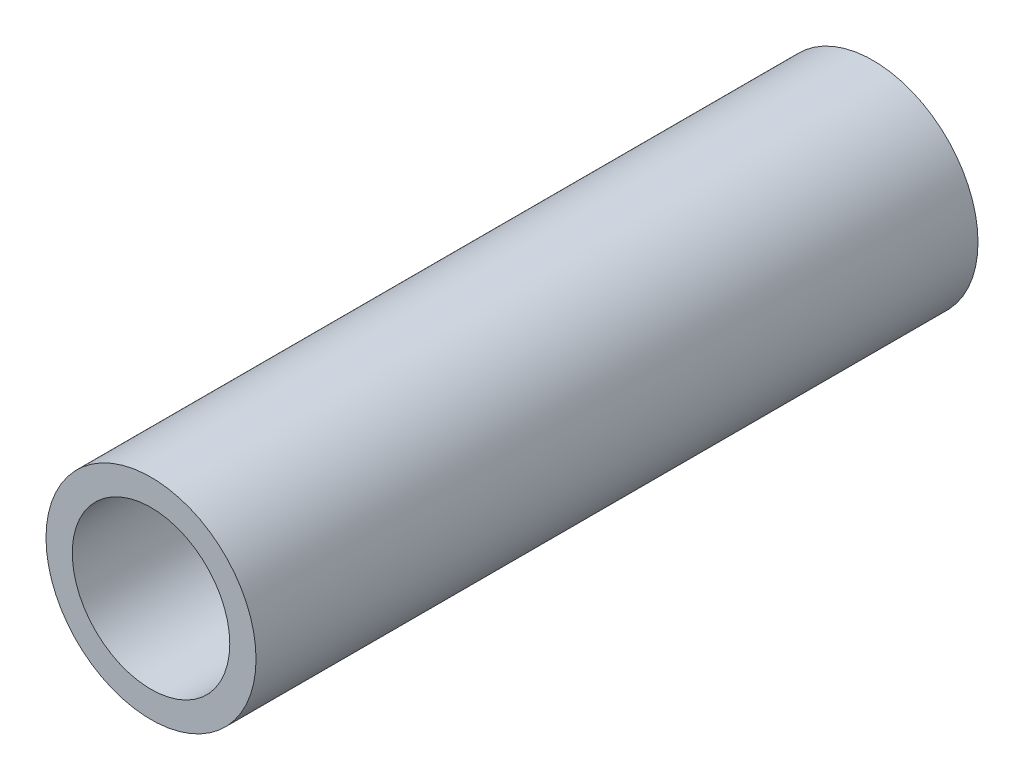
from build123d import *

# Parameters (mm, degrees)
SKETCH_1_R      = 8
SKETCH_1_R_2    = 6
EXTRUDE_1_DEPTH = 55


with BuildPart() as part:
    # 草图1 → 凸台-拉伸1 (new body)
    with BuildSketch(Plane.XY):
        Circle(SKETCH_1_R)
        Circle(SKETCH_1_R_2, mode=Mode.SUBTRACT)
    extrude(amount=EXTRUDE_1_DEPTH)


solid = part.part
